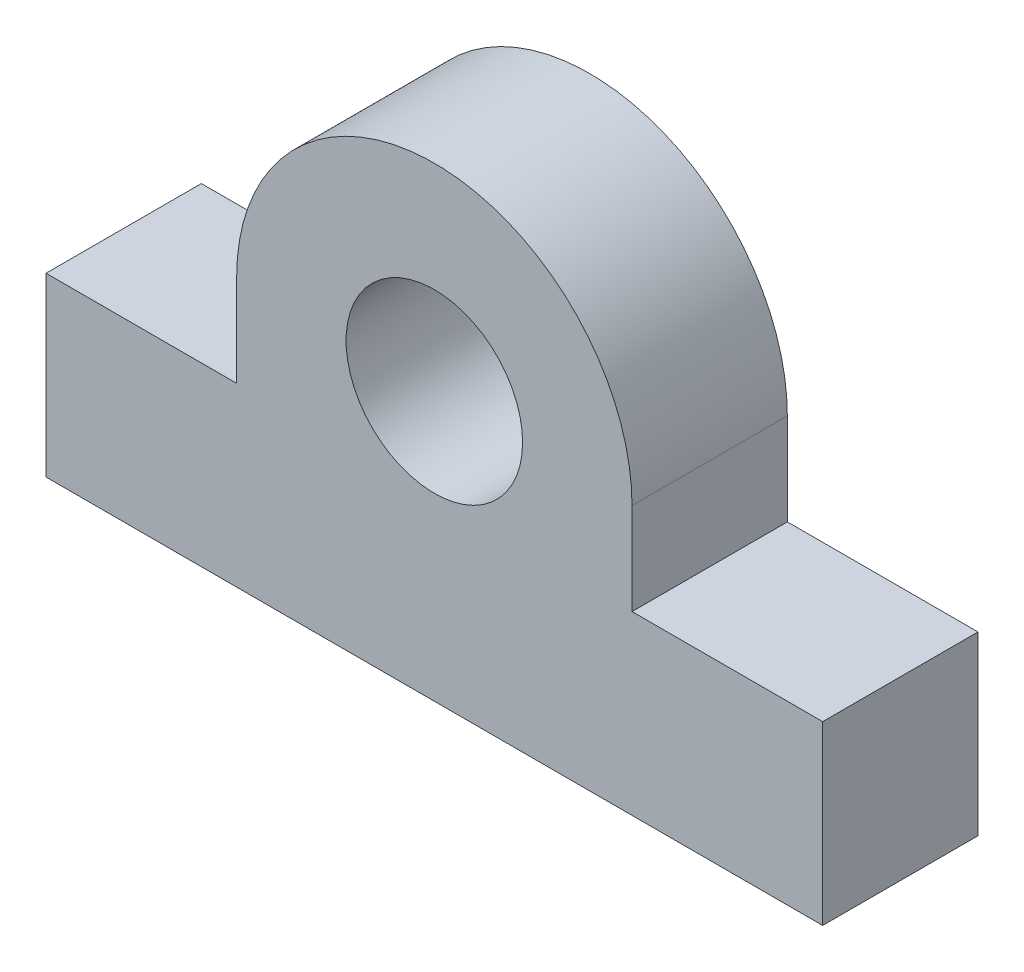
from build123d import *

# Parameters (mm, degrees)
SKETCH1_R           = 12.5
BOSS_EXTRUDE1_DEPTH = 11


with BuildPart() as part:
    # Sketch1 → Boss-Extrude1 (new body, symmetric)
    with BuildSketch(Plane.XY):
        with BuildLine():
            Line((-55, 0), (55, 0))
            Line((55, 0), (55, 25))
            Line((55, 25), (28, 25))
            Line((28, 25), (28, 38))
            ThreePointArc((28, 38), (0, 66), (-28, 38))
            Line((-28, 38), (-28, 25))
            Line((-28, 25), (-55, 25))
            Line((-55, 25), (-55, 0))
        make_face()
        with Locations((0, 38)):
            Circle(SKETCH1_R, mode=Mode.SUBTRACT)
    extrude(amount=BOSS_EXTRUDE1_DEPTH, both=True)


solid = part.part
